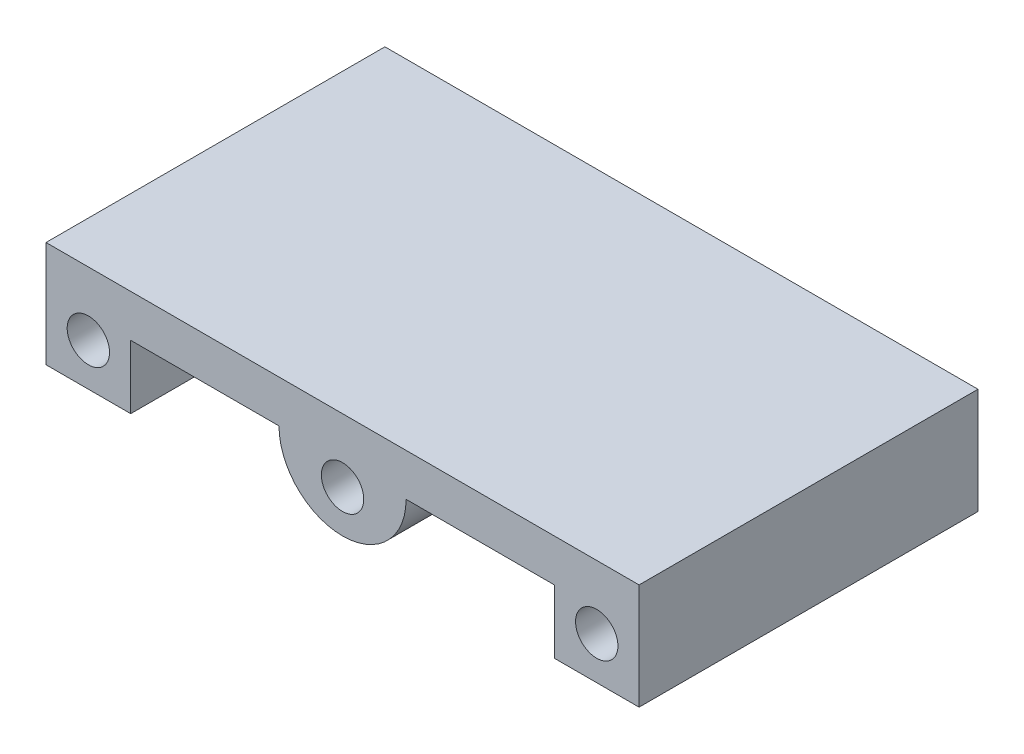
from build123d import *

# Parameters (mm, degrees)
SKETCH1_W           = 177.8
SKETCH1_H           = 101.6
BOSS_EXTRUDE1_DEPTH = 12.7
BOSS_EXTRUDE2_DEPTH = 101.6
SKETCH3_R           = 6.35
CUT_EXTRUDE1_DEPTH  = 101.6
SKETCH4_W           = 25.4
SKETCH4_H           = 19.05
BOSS_EXTRUDE3_DEPTH = 101.6
SKETCH5_R           = 6.35
CUT_EXTRUDE2_DEPTH  = 101.6


with BuildPart() as part:
    # Sketch1 → Boss-Extrude1 (new body)
    with BuildSketch(Plane(origin=(0, 0, 0), x_dir=(1, 0, 0), z_dir=(0, 1, 0))):
        Rectangle(SKETCH1_W, SKETCH1_H)
    extrude(amount=BOSS_EXTRUDE1_DEPTH)

    # Sketch2 → Boss-Extrude2 (add)
    with BuildSketch(Plane.XY.offset(50.8)):
        with BuildLine():
            Line((-19.05, 0), (19.05, 0))
            ThreePointArc((19.05, 0), (0, -19.05), (-19.05, 0))
        make_face()
    extrude(amount=-BOSS_EXTRUDE2_DEPTH)

    # Sketch3 → Cut-Extrude1 (cut)
    with BuildSketch(Plane.XY.offset(50.8)):
        with Locations((0, -6.35)):
            Circle(SKETCH3_R)
    extrude(amount=-CUT_EXTRUDE1_DEPTH, mode=Mode.SUBTRACT)

    # Sketch4 → Boss-Extrude3 (add)
    with BuildSketch(Plane.XY.offset(50.8)):
        with Locations((-76.2, -9.525)):
            Rectangle(SKETCH4_W, SKETCH4_H)
    boss_extrude3 = extrude(amount=-BOSS_EXTRUDE3_DEPTH)

    # Mirror1: Boss-Extrude3 across plane
    add(boss_extrude3.mirror(Plane(origin=(0, 0, 0), x_dir=(0, 0, 1), z_dir=(1, 0, 0))))

    # Sketch5 → Cut-Extrude2 (cut)
    with BuildSketch(Plane.XY.offset(50.8)):
        with Locations((-76.2, -6.35)):
            Circle(SKETCH5_R)
        with Locations((76.2, -6.35)):
            Circle(SKETCH5_R)
    extrude(amount=-CUT_EXTRUDE2_DEPTH, mode=Mode.SUBTRACT)


solid = part.part
